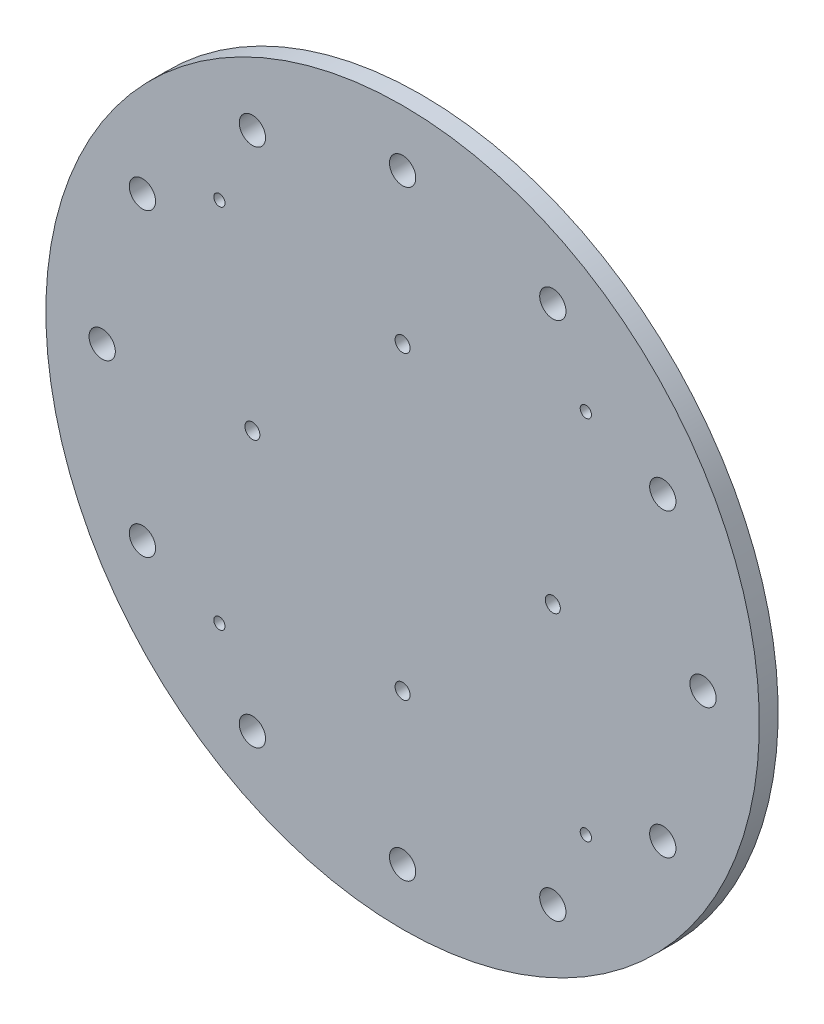
from build123d import *

# Parameters (mm, degrees)
SKETCH1_R             = 95
SKETCH1_R_2           = 1.5
SKETCH1_R_3           = 2
SKETCH1_R_4           = 3.5
BOSS_EXTRUDE1_DEPTH   = 5
BODY_MOVE_COPY1_ANGLE = 90


with BuildPart() as part:
    # Sketch1 → Boss-Extrude1 (new body)
    with BuildSketch(Plane(origin=(0, 0, 0), x_dir=(1, 0, 0), z_dir=(0, 1, 0))):
        Circle(SKETCH1_R)
        with Locations((48.790367902, 48.790367902)):
            Circle(SKETCH1_R_2, mode=Mode.SUBTRACT)
        with Locations((0, 40)):
            Circle(SKETCH1_R_3, mode=Mode.SUBTRACT)
        with Locations((40, 0)):
            Circle(SKETCH1_R_3, mode=Mode.SUBTRACT)
        with Locations((0, -40)):
            Circle(SKETCH1_R_3, mode=Mode.SUBTRACT)
        with Locations((-40, 0)):
            Circle(SKETCH1_R_3, mode=Mode.SUBTRACT)
        with Locations((48.790367902, -48.790367902)):
            Circle(SKETCH1_R_2, mode=Mode.SUBTRACT)
        with Locations((-48.790367902, -48.790367902)):
            Circle(SKETCH1_R_2, mode=Mode.SUBTRACT)
        with Locations((-48.790367902, 48.790367902)):
            Circle(SKETCH1_R_2, mode=Mode.SUBTRACT)
        with Locations((80, 0)):
            Circle(SKETCH1_R_4, mode=Mode.SUBTRACT)
        with Locations((69.282032303, -40)):
            Circle(SKETCH1_R_4, mode=Mode.SUBTRACT)
        with Locations((40, -69.282032303)):
            Circle(SKETCH1_R_4, mode=Mode.SUBTRACT)
        with Locations((0, -80)):
            Circle(SKETCH1_R_4, mode=Mode.SUBTRACT)
        with Locations((-40, -69.282032303)):
            Circle(SKETCH1_R_4, mode=Mode.SUBTRACT)
        with Locations((-69.282032303, -40)):
            Circle(SKETCH1_R_4, mode=Mode.SUBTRACT)
        with Locations((-80, 0)):
            Circle(SKETCH1_R_4, mode=Mode.SUBTRACT)
        with Locations((-69.282032303, 40)):
            Circle(SKETCH1_R_4, mode=Mode.SUBTRACT)
        with Locations((-40, 69.282032303)):
            Circle(SKETCH1_R_4, mode=Mode.SUBTRACT)
        with Locations((0, 80)):
            Circle(SKETCH1_R_4, mode=Mode.SUBTRACT)
        with Locations((40, 69.282032303)):
            Circle(SKETCH1_R_4, mode=Mode.SUBTRACT)
        with Locations((69.282032303, 40)):
            Circle(SKETCH1_R_4, mode=Mode.SUBTRACT)
    extrude(amount=BOSS_EXTRUDE1_DEPTH)


with BuildPart() as part_1:
    # Body-Move/Copy1: moved
    add(part.part.rotate(Axis((0, 2.5, 0), (1, 0, 0)), BODY_MOVE_COPY1_ANGLE))


solid = part_1.part
